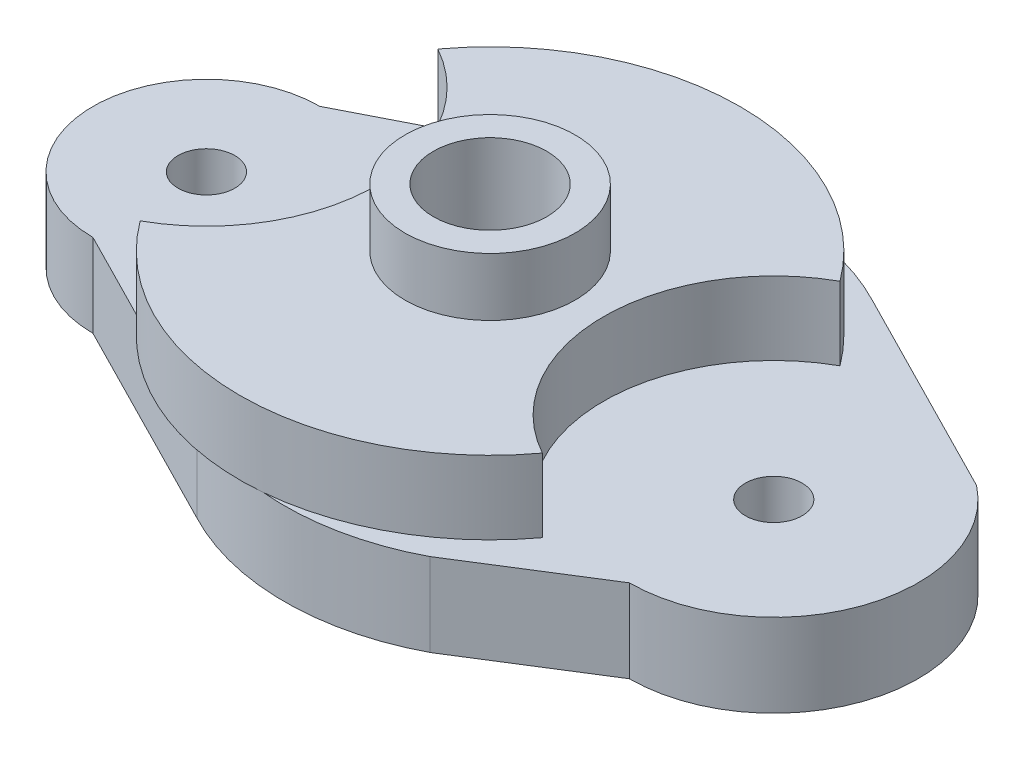
from build123d import *

# Parameters (mm, degrees)
SKETCH2_R           = 9.525
SKETCH2_R_2         = 6.35
BOSS_EXTRUDE1_DEPTH = 14.699996
BOSS_EXTRUDE2_DEPTH = 9.3000068
SKETCH4_R           = 6.35
CUT_EXTRUDE1_DEPTH  = 2540
SKETCH5_R           = 3.175
CUT_EXTRUDE2_DEPTH  = 2540
SKETCH6_R           = 28
SKETCH6_R_2         = 7.320365212
BOSS_EXTRUDE3_DEPTH = 8.200009
SKETCH8_R           = 19.05
CUT_EXTRUDE3_DEPTH  = 8.200009


with BuildPart() as part:
    # Sketch2 → Boss-Extrude1 (new body)
    with BuildSketch(Plane(origin=(0, 0, 0), x_dir=(1, 0, 0), z_dir=(0, 1, 0))):
        Circle(SKETCH2_R)
        Circle(SKETCH2_R_2, mode=Mode.SUBTRACT)
    extrude(amount=BOSS_EXTRUDE1_DEPTH)

    # Sketch3 → Boss-Extrude2 (add)
    with BuildSketch(Plane.XZ):
        with BuildLine():
            Line((-31.75, -12.7), (-8.058170349, -24.768612943))
            ThreePointArc((-8.058170349, -24.768612943), (5, -28), (18.058170349, -24.768612943))
            Line((18.058170349, -24.768612943), (41.75, -12.7))
            ThreePointArc((41.75, -12.7), (47.023813104, 5.291562459), (31.75, 16.164467204))
            Line((31.75, 16.164467204), (18.058170349, 24.768612943))
            ThreePointArc((18.058170349, 24.768612943), (5, 28), (-8.058170349, 24.768612943))
            Line((-8.058170349, 24.768612943), (-31.75, 12.7))
            ThreePointArc((-31.75, 12.7), (-44.45, 0), (-31.75, -12.7))
        make_face()
    extrude(amount=BOSS_EXTRUDE2_DEPTH)

    # Sketch4 → Cut-Extrude1 (cut)
    with BuildSketch(Plane(origin=(0, 0, 0), x_dir=(1, 0, 0), z_dir=(0, 1, 0))):
        Circle(SKETCH4_R)
    extrude(amount=-CUT_EXTRUDE1_DEPTH, mode=Mode.SUBTRACT)

    # Sketch5 → Cut-Extrude2 (cut)
    with BuildSketch(Plane(origin=(0, 0, 0), x_dir=(1, 0, 0), z_dir=(0, 1, 0))):
        with Locations((-31.75, 0)):
            Circle(SKETCH5_R)
        with Locations((31.75, 0)):
            Circle(SKETCH5_R)
    extrude(amount=-CUT_EXTRUDE2_DEPTH, mode=Mode.SUBTRACT)

    # Sketch6 → Boss-Extrude3 (add)
    with BuildSketch(Plane(origin=(0, 0, 0), x_dir=(1, 0, 0), z_dir=(0, 1, 0))):
        Circle(SKETCH6_R)
        Circle(SKETCH6_R_2, mode=Mode.SUBTRACT)
    extrude(amount=BOSS_EXTRUDE3_DEPTH)

    # Sketch8 → Cut-Extrude3 (cut)
    with BuildSketch(Plane(origin=(0, 8.200009, 0), x_dir=(1, 0, 0), z_dir=(0, 1, 0))):
        with Locations((-31.75, 0)):
            Circle(SKETCH8_R)
        with Locations((31.75, 0)):
            Circle(SKETCH8_R)
    extrude(amount=-CUT_EXTRUDE3_DEPTH, mode=Mode.SUBTRACT)


solid = part.part
